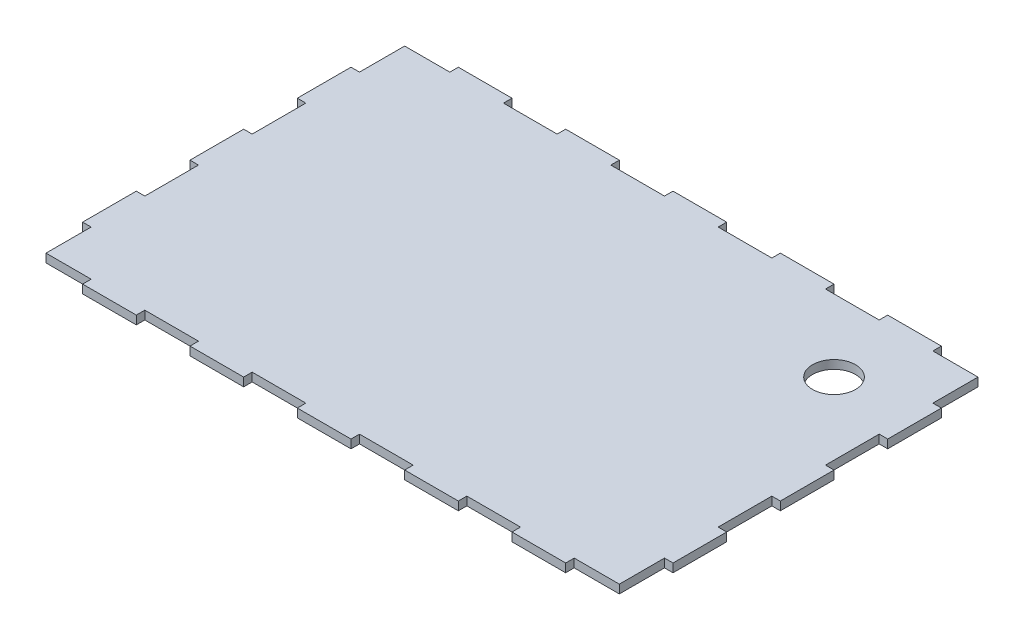
from build123d import *

# Parameters (mm, degrees)
SKETCH48_W           = 219.999999786
SKETCH48_H           = 140
BOSS_EXTRUDE12_DEPTH = 3.175
SKETCH49_R           = 8
SKETCH49_W           = 20
SKETCH49_H           = 3.175
SKETCH49_W_2         = 3.175
SKETCH49_H_2         = 20
CUT_EXTRUDE24_DEPTH  = 3.175


with BuildPart() as part:
    # Sketch48 → Boss-Extrude12 (new body)
    with BuildSketch(Plane.XZ):
        with Locations((-4.307e-06, 668.101928689)):
            Rectangle(SKETCH48_W, SKETCH48_H)
    extrude(amount=BOSS_EXTRUDE12_DEPTH)

    # Sketch49 → Cut-Extrude24 (cut)
    with BuildSketch(Plane(origin=(0, -3.175, 0), x_dir=(-1, 0, 0), z_dir=(0, -1, 0))):
        with Locations((-79.999995586, -628.101928689)):
            Circle(SKETCH49_R)
        with Locations((60.0000042, -736.514428689)):
            Rectangle(SKETCH49_W, SKETCH49_H)
        Polygon((110.0000042, -738.101928689), (90.0000042, -738.101928689), (90.0000042, -734.926928689), (106.8250042, -734.926928689), (106.8250042, -718.101928689), (110.0000042, -718.101928689), align=None)
        with Locations((20.0000042, -736.514428689)):
            Rectangle(SKETCH49_W, SKETCH49_H)
        with Locations((-19.9999958, -736.514428689)):
            Rectangle(SKETCH49_W, SKETCH49_H)
        with Locations((-59.9999958, -736.514428689)):
            Rectangle(SKETCH49_W, SKETCH49_H)
        Polygon((-89.9999958, -738.101928689), (-89.9999958, -734.926928689), (-106.824995586, -734.926928689), (-106.824995586, -718.101928689), (-109.999995586, -718.101928689), (-109.9999958, -738.101928689), align=None)
        with Locations((60.0000042, -599.689428689)):
            Rectangle(SKETCH49_W, SKETCH49_H)
        Polygon((110.0000042, -598.101928689), (90.0000042, -598.101928689), (90.0000042, -601.276928689), (106.8250042, -601.276928689), (106.8250042, -618.101928689), (110.0000042, -618.101928689), align=None)
        with Locations((20.0000042, -599.689428689)):
            Rectangle(SKETCH49_W, SKETCH49_H)
        with Locations((-19.9999958, -599.689428689)):
            Rectangle(SKETCH49_W, SKETCH49_H)
        with Locations((-59.9999958, -599.689428689)):
            Rectangle(SKETCH49_W, SKETCH49_H)
        Polygon((-89.9999958, -598.101928689), (-89.9999958, -601.276928689), (-106.824995586, -601.276928689), (-106.824995586, -618.101928689), (-109.999995586, -618.101928689), (-109.9999958, -598.101928689), align=None)
        with Locations((108.4125042, -648.101928689)):
            Rectangle(SKETCH49_W_2, SKETCH49_H_2)
        with Locations((108.4125042, -688.101928689)):
            Rectangle(SKETCH49_W_2, SKETCH49_H_2)
        with Locations((-108.412495586, -648.101928689)):
            Rectangle(SKETCH49_W_2, SKETCH49_H_2)
        with Locations((-108.412495586, -688.101928689)):
            Rectangle(SKETCH49_W_2, SKETCH49_H_2)
    extrude(amount=-CUT_EXTRUDE24_DEPTH, mode=Mode.SUBTRACT)


solid = part.part
